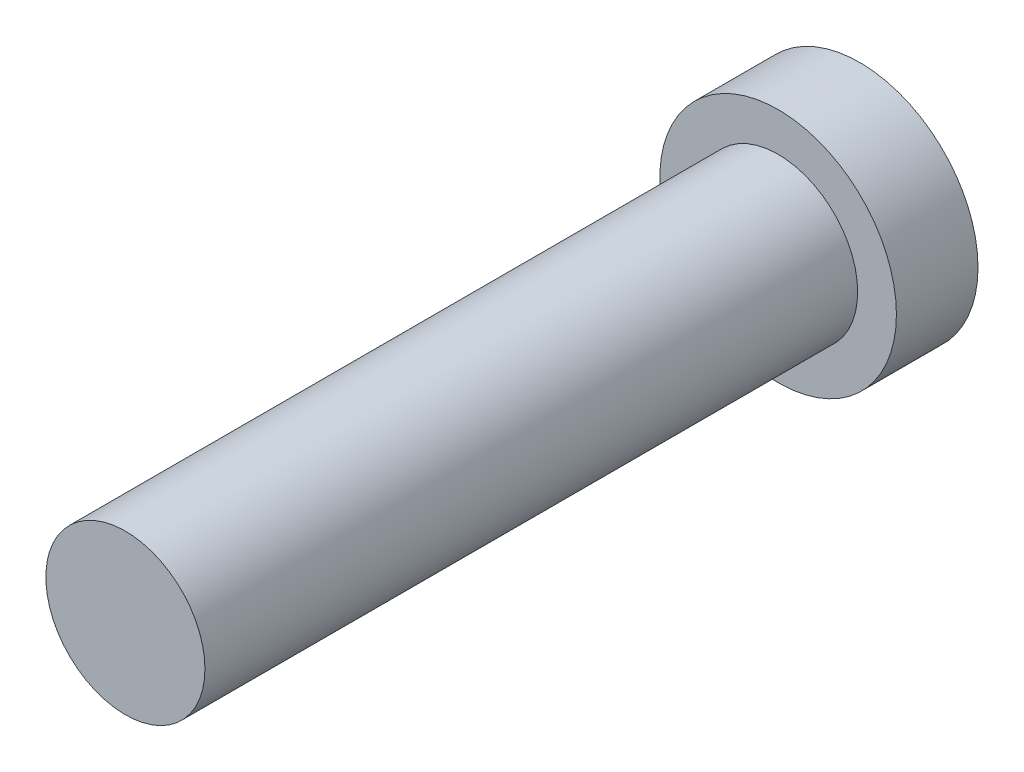
from build123d import *

# Parameters (mm, degrees)
SKETCH1_R           = 2.9
BOSS_EXTRUDE1_DEPTH = 2
SKETCH2_R           = 1.95
BOSS_EXTRUDE2_DEPTH = 16


with BuildPart() as part:
    # Sketch1 → Boss-Extrude1 (new body)
    with BuildSketch(Plane.XY):
        Circle(SKETCH1_R)
    extrude(amount=BOSS_EXTRUDE1_DEPTH)

    # Sketch2 → Boss-Extrude2 (add)
    with BuildSketch(Plane.XY.offset(2)):
        Circle(SKETCH2_R)
    extrude(amount=BOSS_EXTRUDE2_DEPTH)


solid = part.part
